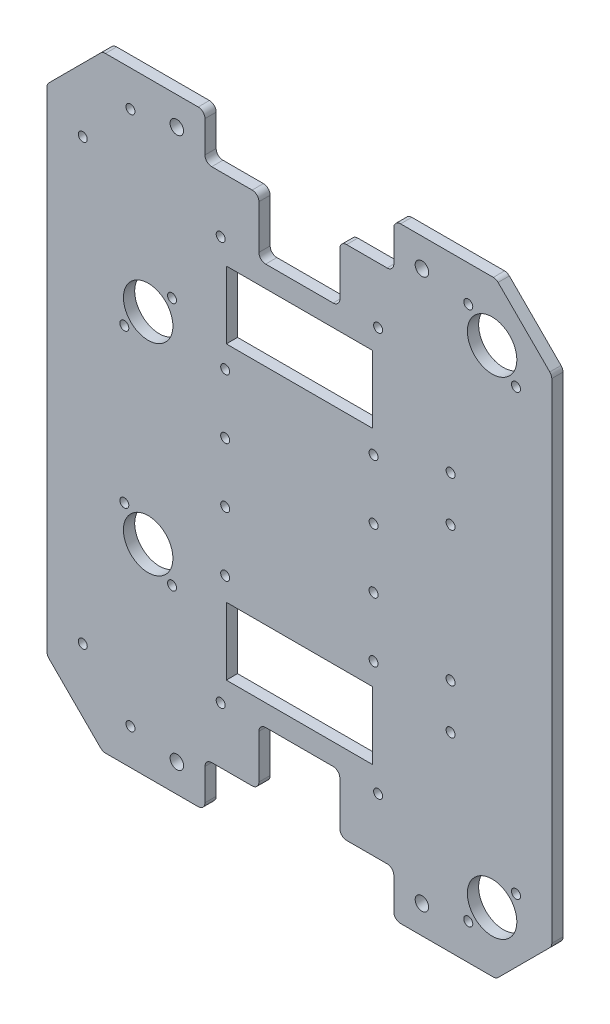
from build123d import *

# Parameters (mm, degrees)
BASE_DEPTH                = 5
ESQUISSE3_R               = 2
ESQUISSE3_W               = 65
ESQUISSE3_H               = 30
ENL_V_MAT_EXTRU_1_DEPTH   = 6
CONG_1_R                  = 3
PER_AGE_POUR_BILLES_REACH = 7
ESQUISSE6_R               = 2
ESQUISSE6_R_2             = 11
PER_AGE_POUR_PROFIL_REACH = 7
ESQUISSE8_R               = 3
ESQUISSE10_R              = 2
ENL_V_MAT_EXTRU_3_DEPTH   = 6
ESQUISSE13_R              = 2
ENL_V_MAT_EXTRU_4_DEPTH   = 10


with BuildPart() as part:
    # Esquisse1 → Base (new body)
    with BuildSketch(Plane.XY):
        Polygon((0, 0), (-175, 0), (-199.748737342, 24.748737342), (-199.748737342, 244.748737342), (-175, 269.497474683), (0, 269.497474683), (24.748737342, 244.748737342), (24.748737342, 24.748737342), align=None)
    extrude(amount=BASE_DEPTH)

    # Esquisse3 → Enlèv. mat.-Extru.1 (cut, through all)
    with BuildSketch(Plane(origin=(0, 0, 0), x_dir=(-1, 0, 0), z_dir=(0, 0, -1))):
        with Locations((52.5, 45)):
            Circle(ESQUISSE3_R)
        with Locations((122.5, 45)):
            Circle(ESQUISSE3_R)
        with Locations((122.5, 224.497474683)):
            Circle(ESQUISSE3_R)
        with Locations((52.5, 224.497474683)):
            Circle(ESQUISSE3_R)
        Polygon((129.5, 0), (129.5, 20), (105.5, 20), (105.5, 45.5), (69.5, 45.5), (69.5, 20), (45.5, 20), (45.5, 0), align=None)
        Polygon((45.5, 269.497474683), (129.5, 269.497474683), (129.5, 249.497474683), (105.5, 249.497474683), (105.5, 223.997474683), (69.5, 223.997474683), (69.5, 249.497474683), (45.5, 249.497474683), align=None)
        with Locations((87.5, 199.497474683)):
            Rectangle(ESQUISSE3_W, ESQUISSE3_H)
        with Locations((87.5, 70)):
            Rectangle(ESQUISSE3_W, ESQUISSE3_H)
    extrude(amount=-ENL_V_MAT_EXTRU_1_DEPTH, mode=Mode.SUBTRACT)

    # Congé1
    cong_1_edges = [part.edges().sort_by_distance(p)[0] for p in [
        (0, 0, 2.5),
        (-175, 0, 2.5),
        (-199.748737342, 24.748737342, 2.5),
        (-199.748737342, 244.748737342, 2.5),
        (-175, 269.497474683, 2.5),
        (0, 269.497474683, 2.5),
        (24.748737342, 244.748737342, 2.5),
        (24.748737342, 24.748737342, 2.5),
        (-45.5, 249.497474683, 2.5),
        (-45.5, 269.497474683, 2.5),
        (-129.5, 269.497474683, 2.5),
        (-129.5, 249.497474683, 2.5),
        (-105.5, 249.497474683, 2.5),
        (-105.5, 223.997474683, 2.5),
        (-69.5, 223.997474683, 2.5),
        (-69.5, 249.497474683, 2.5),
        (-129.5, 0, 2.5),
        (-45.5, 0, 2.5),
        (-45.5, 20, 2.5),
        (-69.5, 20, 2.5),
        (-69.5, 45.5, 2.5),
        (-105.5, 45.5, 2.5),
        (-105.5, 20, 2.5),
        (-129.5, 20, 2.5),
    ]]
    fillet(cong_1_edges, radius=CONG_1_R)

    # Esquisse6 → Perçage pour billes (cut, up to next)
    with BuildSketch(Plane.XY.offset(5), mode=Mode.PRIVATE) as per_age_pour_billes_sk1:
        with Locations((-12.390872965, 15.893398282)):
            Circle(ESQUISSE6_R)
    per_age_pour_billes_tool1 = extrude(per_age_pour_billes_sk1.sketch, amount=-PER_AGE_POUR_BILLES_REACH, mode=Mode.PRIVATE) & part.part
    add(per_age_pour_billes_tool1.solids().sort_by_distance((-12.390873, 15.893398, 5))[0], mode=Mode.SUBTRACT)
    # Esquisse6 → Perçage pour billes (cut, up to next)
    with BuildSketch(Plane.XY.offset(5), mode=Mode.PRIVATE) as per_age_pour_billes_sk2:
        with Locations((8.82233047, 37.106601718)):
            Circle(ESQUISSE6_R)
    per_age_pour_billes_tool2 = extrude(per_age_pour_billes_sk2.sketch, amount=-PER_AGE_POUR_BILLES_REACH, mode=Mode.PRIVATE) & part.part
    add(per_age_pour_billes_tool2.solids().sort_by_distance((8.82233, 37.106602, 5))[0], mode=Mode.SUBTRACT)
    # Esquisse6 → Perçage pour billes (cut, up to next)
    with BuildSketch(Plane.XY.offset(5), mode=Mode.PRIVATE) as per_age_pour_billes_sk3:
        with Locations((8.82233047, 232.390872965)):
            Circle(ESQUISSE6_R)
    per_age_pour_billes_tool3 = extrude(per_age_pour_billes_sk3.sketch, amount=-PER_AGE_POUR_BILLES_REACH, mode=Mode.PRIVATE) & part.part
    add(per_age_pour_billes_tool3.solids().sort_by_distance((8.82233, 232.390873, 5))[0], mode=Mode.SUBTRACT)
    # Esquisse6 → Perçage pour billes (cut, up to next)
    with BuildSketch(Plane.XY.offset(5), mode=Mode.PRIVATE) as per_age_pour_billes_sk4:
        with Locations((-12.390872965, 253.604076401)):
            Circle(ESQUISSE6_R)
    per_age_pour_billes_tool4 = extrude(per_age_pour_billes_sk4.sketch, amount=-PER_AGE_POUR_BILLES_REACH, mode=Mode.PRIVATE) & part.part
    add(per_age_pour_billes_tool4.solids().sort_by_distance((-12.390873, 253.604076, 5))[0], mode=Mode.SUBTRACT)
    # Esquisse6 → Perçage pour billes (cut, up to next)
    with BuildSketch(Plane.XY.offset(5), mode=Mode.PRIVATE) as per_age_pour_billes_sk5:
        with Locations((-1.784271247, 242.997474683)):
            Circle(ESQUISSE6_R_2)
    per_age_pour_billes_tool5 = extrude(per_age_pour_billes_sk5.sketch, amount=-PER_AGE_POUR_BILLES_REACH, mode=Mode.PRIVATE) & part.part
    add(per_age_pour_billes_tool5.solids().sort_by_distance((-1.784271, 242.997475, 5))[0], mode=Mode.SUBTRACT)
    # Esquisse6 → Perçage pour billes (cut, up to next)
    with BuildSketch(Plane.XY.offset(5), mode=Mode.PRIVATE) as per_age_pour_billes_sk6:
        with Locations((-1.784271247, 26.5)):
            Circle(ESQUISSE6_R_2)
    per_age_pour_billes_tool6 = extrude(per_age_pour_billes_sk6.sketch, amount=-PER_AGE_POUR_BILLES_REACH, mode=Mode.PRIVATE) & part.part
    add(per_age_pour_billes_tool6.solids().sort_by_distance((-1.784271, 26.5, 5))[0], mode=Mode.SUBTRACT)
    # Esquisse6 → Perçage pour billes (cut, up to next)
    with BuildSketch(Plane.XY.offset(5), mode=Mode.PRIVATE) as per_age_pour_billes_sk7:
        with Locations((-144.142135624, 190.104076401)):
            Circle(ESQUISSE6_R)
    per_age_pour_billes_tool7 = extrude(per_age_pour_billes_sk7.sketch, amount=-PER_AGE_POUR_BILLES_REACH, mode=Mode.PRIVATE) & part.part
    add(per_age_pour_billes_tool7.solids().sort_by_distance((-144.142136, 190.104076, 5))[0], mode=Mode.SUBTRACT)
    # Esquisse6 → Perçage pour billes (cut, up to next)
    with BuildSketch(Plane.XY.offset(5), mode=Mode.PRIVATE) as per_age_pour_billes_sk8:
        with Locations((-165.355339059, 168.890872965)):
            Circle(ESQUISSE6_R)
    per_age_pour_billes_tool8 = extrude(per_age_pour_billes_sk8.sketch, amount=-PER_AGE_POUR_BILLES_REACH, mode=Mode.PRIVATE) & part.part
    add(per_age_pour_billes_tool8.solids().sort_by_distance((-165.355339, 168.890873, 5))[0], mode=Mode.SUBTRACT)
    # Esquisse6 → Perçage pour billes (cut, up to next)
    with BuildSketch(Plane.XY.offset(5), mode=Mode.PRIVATE) as per_age_pour_billes_sk9:
        with Locations((-154.748737342, 179.497474683)):
            Circle(ESQUISSE6_R_2)
    per_age_pour_billes_tool9 = extrude(per_age_pour_billes_sk9.sketch, amount=-PER_AGE_POUR_BILLES_REACH, mode=Mode.PRIVATE) & part.part
    add(per_age_pour_billes_tool9.solids().sort_by_distance((-154.748737, 179.497475, 5))[0], mode=Mode.SUBTRACT)
    # Esquisse6 → Perçage pour billes (cut, up to next)
    with BuildSketch(Plane.XY.offset(5), mode=Mode.PRIVATE) as per_age_pour_billes_sk10:
        with Locations((-165.355339059, 100.606601718)):
            Circle(ESQUISSE6_R)
    per_age_pour_billes_tool10 = extrude(per_age_pour_billes_sk10.sketch, amount=-PER_AGE_POUR_BILLES_REACH, mode=Mode.PRIVATE) & part.part
    add(per_age_pour_billes_tool10.solids().sort_by_distance((-165.355339, 100.606602, 5))[0], mode=Mode.SUBTRACT)
    # Esquisse6 → Perçage pour billes (cut, up to next)
    with BuildSketch(Plane.XY.offset(5), mode=Mode.PRIVATE) as per_age_pour_billes_sk11:
        with Locations((-154.748737342, 90)):
            Circle(ESQUISSE6_R_2)
    per_age_pour_billes_tool11 = extrude(per_age_pour_billes_sk11.sketch, amount=-PER_AGE_POUR_BILLES_REACH, mode=Mode.PRIVATE) & part.part
    add(per_age_pour_billes_tool11.solids().sort_by_distance((-154.748737, 90, 5))[0], mode=Mode.SUBTRACT)
    # Esquisse6 → Perçage pour billes (cut, up to next)
    with BuildSketch(Plane.XY.offset(5), mode=Mode.PRIVATE) as per_age_pour_billes_sk12:
        with Locations((-144.142135624, 79.393398282)):
            Circle(ESQUISSE6_R)
    per_age_pour_billes_tool12 = extrude(per_age_pour_billes_sk12.sketch, amount=-PER_AGE_POUR_BILLES_REACH, mode=Mode.PRIVATE) & part.part
    add(per_age_pour_billes_tool12.solids().sort_by_distance((-144.142136, 79.393398, 5))[0], mode=Mode.SUBTRACT)
    # Esquisse6 → Perçage pour billes (cut, up to next)
    with BuildSketch(Plane.XY.offset(5), mode=Mode.PRIVATE) as per_age_pour_billes_sk13:
        with Locations((-183.838834765, 37.123106012)):
            Circle(ESQUISSE6_R)
    per_age_pour_billes_tool13 = extrude(per_age_pour_billes_sk13.sketch, amount=-PER_AGE_POUR_BILLES_REACH, mode=Mode.PRIVATE) & part.part
    add(per_age_pour_billes_tool13.solids().sort_by_distance((-183.838835, 37.123106, 5))[0], mode=Mode.SUBTRACT)
    # Esquisse6 → Perçage pour billes (cut, up to next)
    with BuildSketch(Plane.XY.offset(5), mode=Mode.PRIVATE) as per_age_pour_billes_sk14:
        with Locations((-162.625631329, 15.909902577)):
            Circle(ESQUISSE6_R)
    per_age_pour_billes_tool14 = extrude(per_age_pour_billes_sk14.sketch, amount=-PER_AGE_POUR_BILLES_REACH, mode=Mode.PRIVATE) & part.part
    add(per_age_pour_billes_tool14.solids().sort_by_distance((-162.625631, 15.909903, 5))[0], mode=Mode.SUBTRACT)
    # Esquisse6 → Perçage pour billes (cut, up to next)
    with BuildSketch(Plane.XY.offset(5), mode=Mode.PRIVATE) as per_age_pour_billes_sk15:
        with Locations((-162.625631329, 253.587572106)):
            Circle(ESQUISSE6_R)
    per_age_pour_billes_tool15 = extrude(per_age_pour_billes_sk15.sketch, amount=-PER_AGE_POUR_BILLES_REACH, mode=Mode.PRIVATE) & part.part
    add(per_age_pour_billes_tool15.solids().sort_by_distance((-162.625631, 253.587572, 5))[0], mode=Mode.SUBTRACT)
    # Esquisse6 → Perçage pour billes (cut, up to next)
    with BuildSketch(Plane.XY.offset(5), mode=Mode.PRIVATE) as per_age_pour_billes_sk16:
        with Locations((-183.838834765, 232.374368671)):
            Circle(ESQUISSE6_R)
    per_age_pour_billes_tool16 = extrude(per_age_pour_billes_sk16.sketch, amount=-PER_AGE_POUR_BILLES_REACH, mode=Mode.PRIVATE) & part.part
    add(per_age_pour_billes_tool16.solids().sort_by_distance((-183.838835, 232.374369, 5))[0], mode=Mode.SUBTRACT)

    # Esquisse8 → Perçage pour profilé (cut, up to next)
    with BuildSketch(Plane.XY.offset(5), mode=Mode.PRIVATE) as per_age_pour_profil_sk1:
        with Locations((-142, 12.5)):
            Circle(ESQUISSE8_R)
    per_age_pour_profil_tool1 = extrude(per_age_pour_profil_sk1.sketch, amount=-PER_AGE_POUR_PROFIL_REACH, mode=Mode.PRIVATE) & part.part
    add(per_age_pour_profil_tool1.solids().sort_by_distance((-142, 12.5, 5))[0], mode=Mode.SUBTRACT)
    # Esquisse8 → Perçage pour profilé (cut, up to next)
    with BuildSketch(Plane.XY.offset(5), mode=Mode.PRIVATE) as per_age_pour_profil_sk2:
        with Locations((-142, 256.997474683)):
            Circle(ESQUISSE8_R)
    per_age_pour_profil_tool2 = extrude(per_age_pour_profil_sk2.sketch, amount=-PER_AGE_POUR_PROFIL_REACH, mode=Mode.PRIVATE) & part.part
    add(per_age_pour_profil_tool2.solids().sort_by_distance((-142, 256.997475, 5))[0], mode=Mode.SUBTRACT)
    # Esquisse8 → Perçage pour profilé (cut, up to next)
    with BuildSketch(Plane.XY.offset(5), mode=Mode.PRIVATE) as per_age_pour_profil_sk3:
        with Locations((-33, 256.997474683)):
            Circle(ESQUISSE8_R)
    per_age_pour_profil_tool3 = extrude(per_age_pour_profil_sk3.sketch, amount=-PER_AGE_POUR_PROFIL_REACH, mode=Mode.PRIVATE) & part.part
    add(per_age_pour_profil_tool3.solids().sort_by_distance((-33, 256.997475, 5))[0], mode=Mode.SUBTRACT)
    # Esquisse8 → Perçage pour profilé (cut, up to next)
    with BuildSketch(Plane.XY.offset(5), mode=Mode.PRIVATE) as per_age_pour_profil_sk4:
        with Locations((-33, 12.5)):
            Circle(ESQUISSE8_R)
    per_age_pour_profil_tool4 = extrude(per_age_pour_profil_sk4.sketch, amount=-PER_AGE_POUR_PROFIL_REACH, mode=Mode.PRIVATE) & part.part
    add(per_age_pour_profil_tool4.solids().sort_by_distance((-33, 12.5, 5))[0], mode=Mode.SUBTRACT)

    # Esquisse10 → Enlèv. mat.-Extru.3 (cut, through all)
    with BuildSketch(Plane.XY.offset(5)):
        with Locations((-120.5, 174.497474683)):
            Circle(ESQUISSE10_R)
        with Locations((-120.5, 147.997474683)):
            Circle(ESQUISSE10_R)
        with Locations((-54.5, 147.997474683)):
            Circle(ESQUISSE10_R)
        with Locations((-54.5, 174.497474683)):
            Circle(ESQUISSE10_R)
        with Locations((-54.5, 121.5)):
            Circle(ESQUISSE10_R)
        with Locations((-54.5, 95)):
            Circle(ESQUISSE10_R)
        with Locations((-120.5, 121.5)):
            Circle(ESQUISSE10_R)
        with Locations((-120.5, 95)):
            Circle(ESQUISSE10_R)
    extrude(amount=-ENL_V_MAT_EXTRU_3_DEPTH, mode=Mode.SUBTRACT)

    # Esquisse13 → Enlèv. mat.-Extru.4 (cut)
    with BuildSketch(Plane.XY.offset(5)):
        with Locations((-20.251262658, 184.748737342)):
            Circle(ESQUISSE13_R)
        with Locations((-20.251262658, 164.748737342)):
            Circle(ESQUISSE13_R)
        with Locations((-20.251262658, 104.748737342)):
            Circle(ESQUISSE13_R)
        with Locations((-20.251262658, 84.748737342)):
            Circle(ESQUISSE13_R)
    extrude(amount=-ENL_V_MAT_EXTRU_4_DEPTH, mode=Mode.SUBTRACT)


solid = part.part
